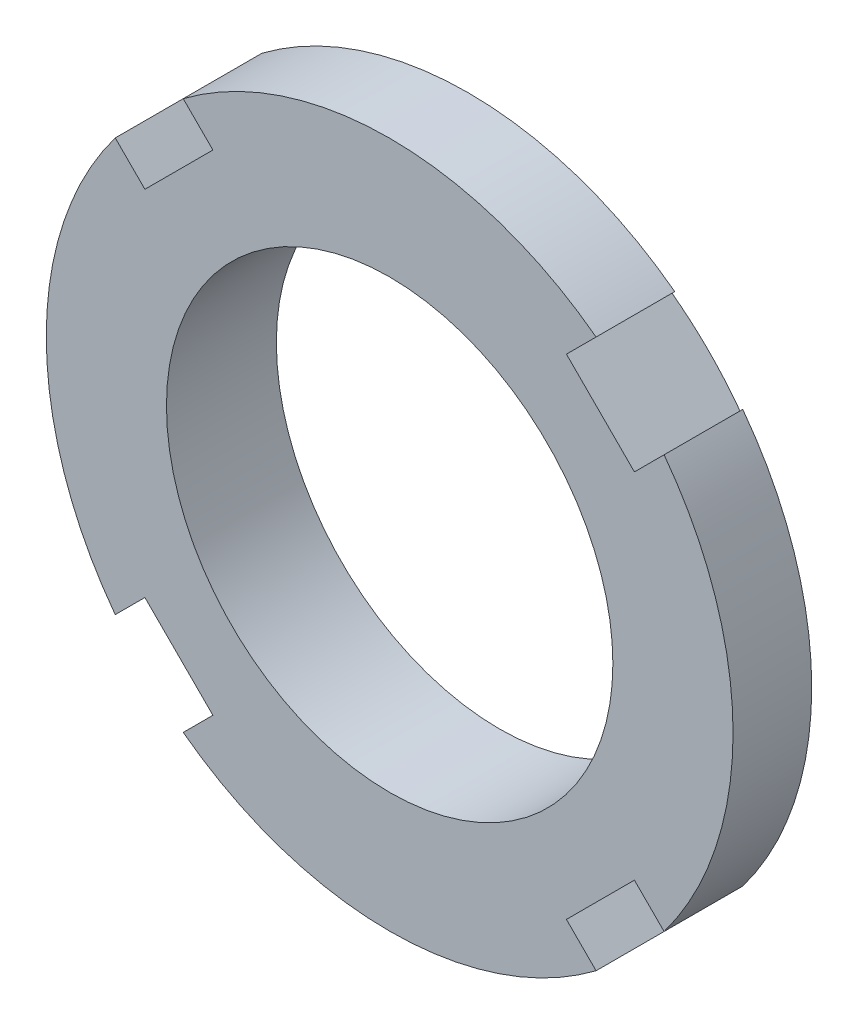
from build123d import *

# Parameters (mm, degrees)
SKETCH1_R          = 25
SKETCH1_R_2        = 16.25
EXTRUDE1_DEPTH     = 8
CUT_EXTRUDE1_DEPTH = 9
CIRPATTERN1_COUNT  = 4


with BuildPart() as part:
    # Sketch1 → Extrude1 (new body)
    with BuildSketch(Plane.XY):
        Circle(SKETCH1_R)
        Circle(SKETCH1_R_2, mode=Mode.SUBTRACT)
    extrude(amount=EXTRUDE1_DEPTH)

    # Sketch2 → Cut-Extrude1 (cut, through all)
    with BuildSketch(Plane.XY.offset(8)):
        with BuildLine():
            Line((15.02869733, 19.978444798), (12.869343418, 17.819090886))
            Line((12.869343418, 17.819090886), (17.819090886, 12.869343418))
            Line((17.819090886, 12.869343418), (19.978444798, 15.02869733))
            ThreePointArc((19.978444798, 15.02869733), (17.67766953, 17.67766953), (15.02869733, 19.978444798))
        make_face()
    cut_extrude1 = extrude(amount=-CUT_EXTRUDE1_DEPTH, mode=Mode.SUBTRACT)

    # CirPattern1: Cut-Extrude1 ×4 about axis
    cirpattern1_axis = Axis((0, 0, 0), (0, 0, 1))
    for i in range(1, CIRPATTERN1_COUNT):
        add(cut_extrude1.rotate(cirpattern1_axis, i * 360 / CIRPATTERN1_COUNT), mode=Mode.SUBTRACT)

    # Sketch3 → Cut-Revolve1 (revolve, cut)
    with BuildSketch(Plane(origin=(0, 0, 0), x_dir=(1, 0, 0), z_dir=(0, 1, 0))):
        Polygon((25, 0), (21.5, 0), (25, -2.272926576), align=None)
    revolve(axis=Axis((0, 0, 0), (0, 0, -1)), mode=Mode.SUBTRACT)


solid = part.part
